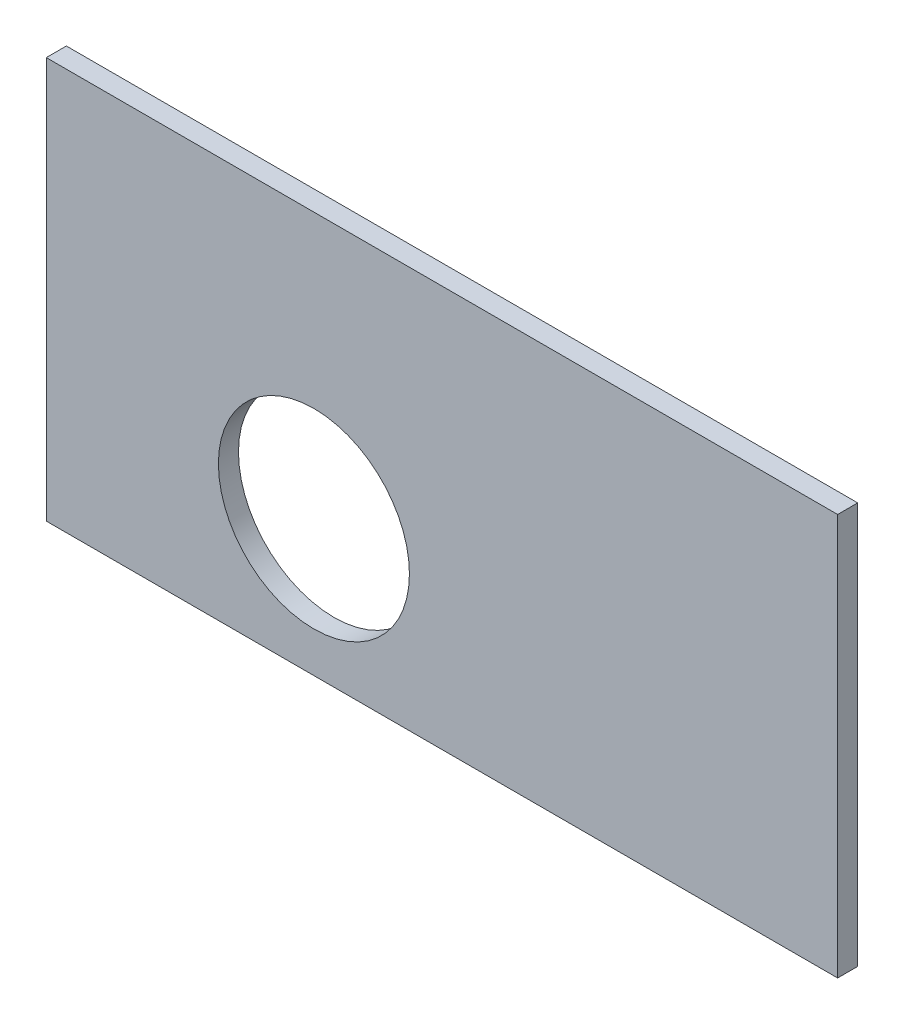
from build123d import *

# Parameters (mm, degrees)
SKETCH1_W           = 118.28
SKETCH1_H           = 60
BOSS_EXTRUDE1_DEPTH = 3
SKETCH2_R           = 14.275
CUT_EXTRUDE1_DEPTH  = 3


with BuildPart() as part:
    # Sketch1 → Boss-Extrude1 (new body)
    with BuildSketch(Plane.XY):
        with Locations((59.14, 30)):
            Rectangle(SKETCH1_W, SKETCH1_H)
    extrude(amount=BOSS_EXTRUDE1_DEPTH)

    # Sketch2 → Cut-Extrude1 (cut)
    with BuildSketch(Plane.XY.offset(3)):
        with Locations((40, 20.31)):
            Circle(SKETCH2_R)
    extrude(amount=-CUT_EXTRUDE1_DEPTH, mode=Mode.SUBTRACT)


solid = part.part
